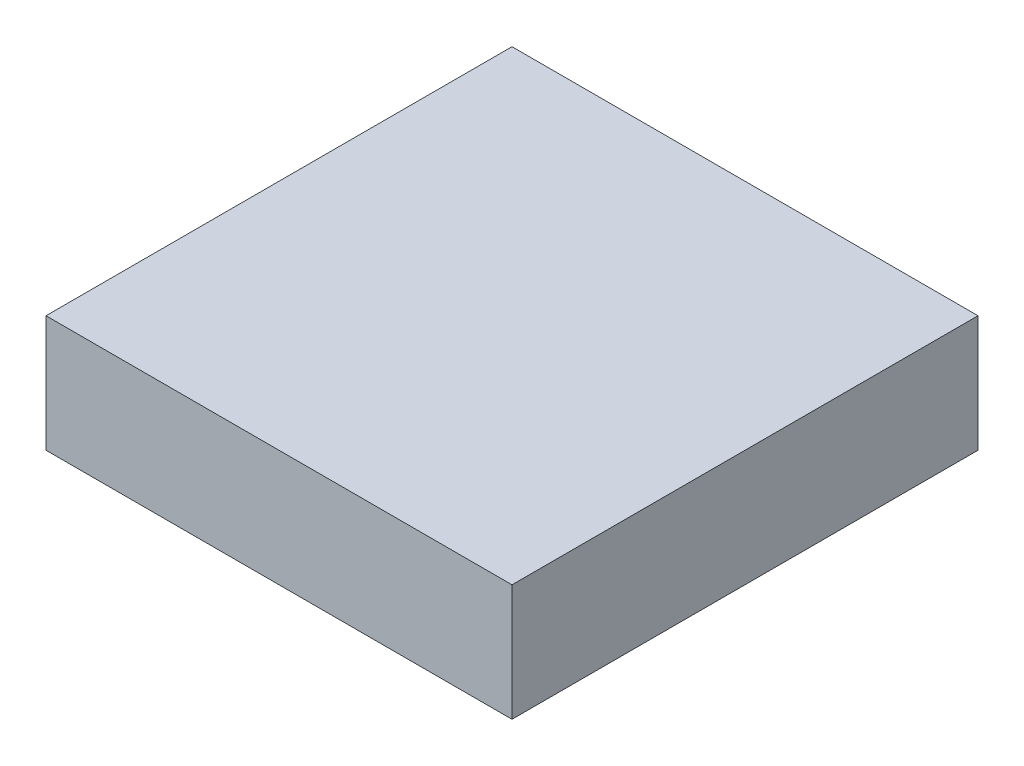
from build123d import *

# Parameters (mm, degrees)
SKETCH1_W           = 20
SKETCH1_H           = 20
BOSS_EXTRUDE1_DEPTH = 5


with BuildPart() as part:
    # Sketch1 → Boss-Extrude1 (new body)
    with BuildSketch(Plane(origin=(0, 0, 0), x_dir=(1, 0, 0), z_dir=(0, 1, 0))):
        Rectangle(SKETCH1_W, SKETCH1_H)
    extrude(amount=BOSS_EXTRUDE1_DEPTH)


solid = part.part
